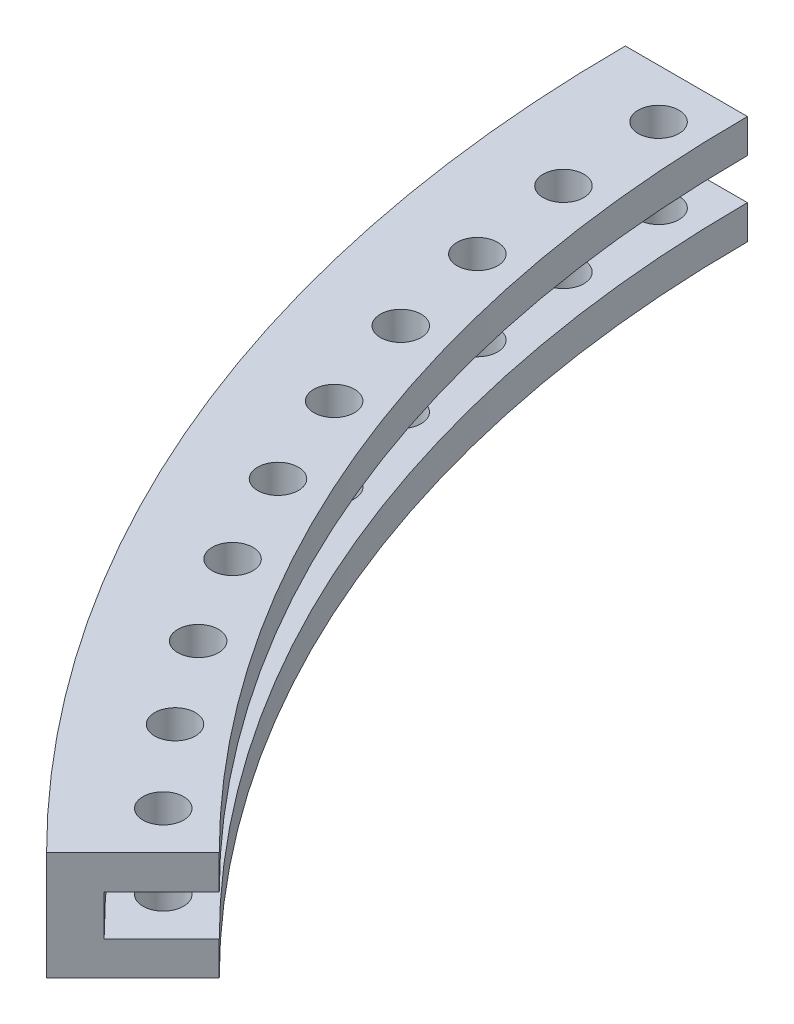
from build123d import *

# Parameters (mm, degrees)
R_VOLUTION1_ANGLE            = 45
ESQUISSE3_R                  = 1.5
ENL_V_MAT_EXTRU_1_DEPTH      = 9
R_P_TITION_CIRCULAIRE1_COUNT = 10
R_P_TITION_CIRCULAIRE1_ANGLE = 40.5


with BuildPart() as part:
    # Esquisse2 → Révolution1 (revolve)
    with BuildSketch(Plane.XY):
        Polygon((-103, 4), (-103, -4), (-94, -4), (-94, -1.5), (-100, -1.5), (-100, 1.5), (-94, 1.5), (-94, 4), align=None)
    revolve(axis=Axis((0, -55, 0), (0, 1, 0)), revolution_arc=R_VOLUTION1_ANGLE)

    # Esquisse3 → Enlèv. mat.-Extru.1 (cut, through all)
    with BuildSketch(Plane(origin=(0, 4, 0), x_dir=(1, 0, 0), z_dir=(0, 1, 0))):
        with Locations((-71.359442001, -65.702587752)):
            Circle(ESQUISSE3_R)
    enl_v_mat_extru_1 = extrude(amount=-ENL_V_MAT_EXTRU_1_DEPTH, mode=Mode.SUBTRACT)

    # Répétition circulaire1: Enlèv. mat.-Extru.1 ×10 about axis
    r_p_tition_circulaire1_axis = Axis((0, 0, 0), (0, -1, 0))
    for i in range(1, R_P_TITION_CIRCULAIRE1_COUNT):
        add(enl_v_mat_extru_1.rotate(r_p_tition_circulaire1_axis, i * R_P_TITION_CIRCULAIRE1_ANGLE / (R_P_TITION_CIRCULAIRE1_COUNT - 1)), mode=Mode.SUBTRACT)


solid = part.part
